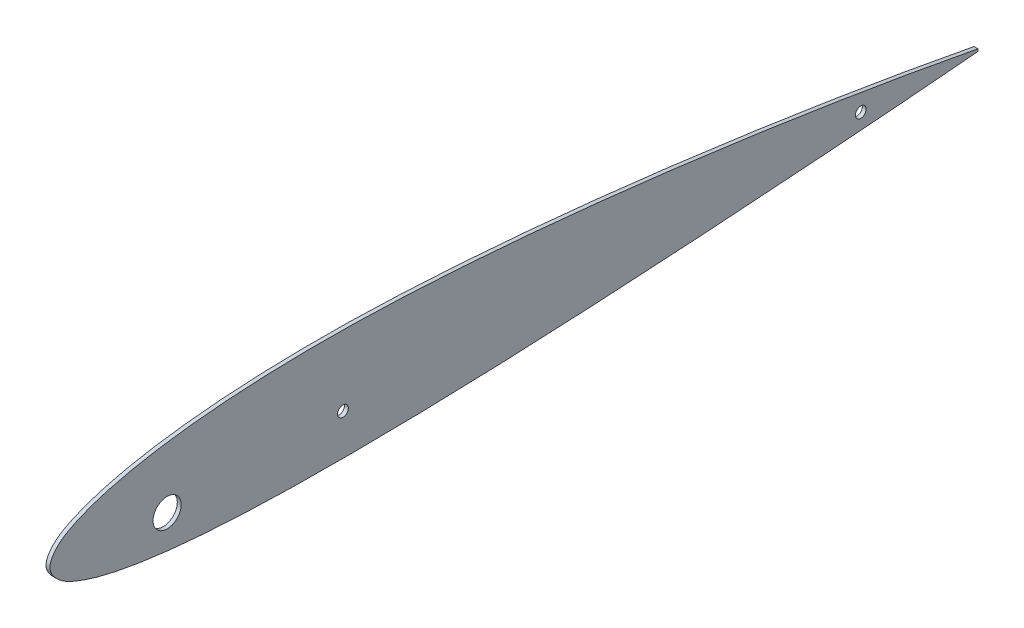
from build123d import *

# Parameters (mm, degrees)
AIRFOIL_RIB_DEPTH     = 2
SPAR_CUTS_R           = 7.19536101
SPAR_CUTS_R_2         = 2.75
SPAR_HOLES_DEPTH      = 3.0000001
SPAR_HOLES_DEPTH_BACK = 1.0000001


with BuildPart() as part:
    # airfoil → airfoil_rib (new body)
    with BuildSketch(Plane(origin=(0, 0, 0), x_dir=(0, 0, -1), z_dir=(1, 0, 0))):
        with BuildLine():
            Line((475.010074803, 0.598497198), (474.989925197, -0.598497198))
            add(Edge.make_bspline(
                [(475.010074803, 0.598497198), (467.158690521, 2.079023629), (451.453860548, 5.040465208), (419.979582043, 10.530372968), (380.568519359, 16.837323679), (333.177066429, 23.50166403), (285.712995661, 29.272162763), (238.176447157, 33.970748215), (190.512569895, 37.418517291), (150.679357097, 38.771778219), (118.758979213, 38.431249281), (94.813200273, 37.391767553), (70.870946514, 35.289097795), (50.961986884, 32.444163764), (35.093906393, 29.060842527), (23.148318138, 25.778613175), (13.103175409, 21.788482809), (4.488169793, 17.004459258), (-2.912341204, 7.900947053), (5.05216125, -0.676100889), (13.883265937, -4.946583673), (24.057193158, -8.354984484), (36.042309654, -11.029852794), (51.86492551, -13.697698003), (71.600645218, -15.867627284), (95.255333151, -17.419108557), (118.863099099, -18.233536289), (150.313877095, -18.621301019), (189.7073278, -18.180783507), (237.048964841, -16.653486427), (284.501569815, -14.340047071), (332.013270591, -11.49353673), (379.598404528, -8.265859738), (419.295052653, -5.278243972), (451.101430606, -2.689224264), (467.020539675, -1.295979827), (474.989925197, -0.598497198)],
                knots=[0, 0, 0, 0, 0.024758353, 0.049523206, 0.099002464, 0.148431641, 0.197816093, 0.247156978, 0.296440501, 0.345884085, 0.370605916, 0.395346156, 0.420138806, 0.445056029, 0.45762203, 0.470360867, 0.483523327, 0.490626325, 0.501772116, 0.512907947, 0.5199771, 0.533052484, 0.545674077, 0.558115541, 0.582725097, 0.607174358, 0.631557279, 0.655916257, 0.704636043, 0.753621853, 0.802687387, 0.851851698, 0.901113053, 0.950481472, 0.975210156, 1, 1, 1, 1], degree=3))
        make_face()
    extrude(amount=AIRFOIL_RIB_DEPTH)

    # spar_cuts → spar_holes (cut, two sides)
    with BuildSketch(Plane(origin=(0, 0, 0), x_dir=(0, 0, -1), z_dir=(1, 0, 0))) as spar_holes_sk:
        with Locations((60, 2.500001882)):
            Circle(SPAR_CUTS_R)
        with Locations((150, 2.500001882)):
            Circle(SPAR_CUTS_R_2)
        with Locations((415.033583383, 2.500001882)):
            Circle(SPAR_CUTS_R_2)
    extrude(amount=SPAR_HOLES_DEPTH, mode=Mode.SUBTRACT)
    extrude(spar_holes_sk.sketch, amount=-SPAR_HOLES_DEPTH_BACK, mode=Mode.SUBTRACT)


solid = part.part
